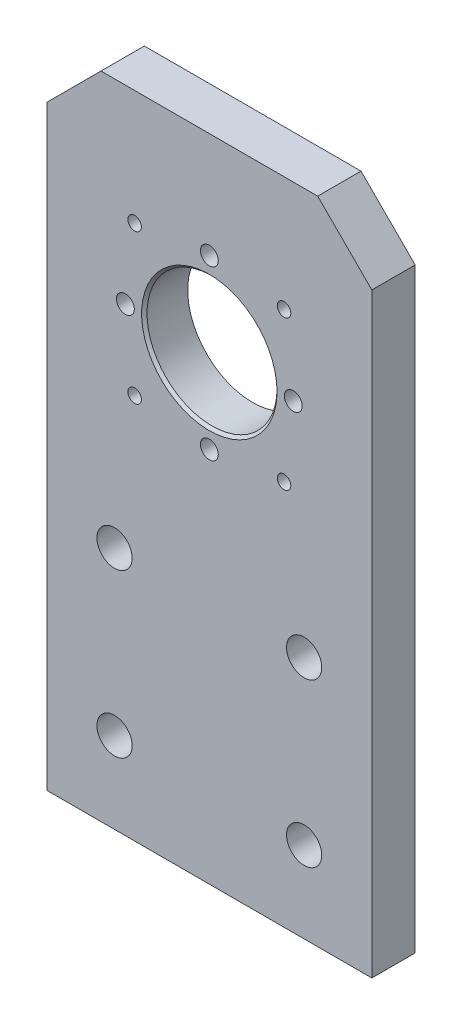
from build123d import *

# Parameters (mm, degrees)
SKETCH1_W           = 60
SKETCH1_H           = 120
SKETCH1_R           = 3.25
SKETCH1_R_2         = 12
BOSS_EXTRUDE1_DEPTH = 8
M3_TAPPED_HOLE1_D   = 2.5
M4_TAPPED_HOLE1_D   = 3.3
CHAMFER1_SIZE       = 0.5
CHAMFER2_SIZE       = 10


with BuildPart() as part:
    # Sketch1 → Boss-Extrude1 (new body)
    with BuildSketch(Plane.XY):
        Rectangle(SKETCH1_W, SKETCH1_H)
        with Locations((-17.5, -15)):
            Circle(SKETCH1_R, mode=Mode.SUBTRACT)
        with Locations((-17.5, -45)):
            Circle(SKETCH1_R, mode=Mode.SUBTRACT)
        with Locations((17.5, -45)):
            Circle(SKETCH1_R, mode=Mode.SUBTRACT)
        with Locations((17.5, -15)):
            Circle(SKETCH1_R, mode=Mode.SUBTRACT)
        with Locations((0, 25)):
            Circle(SKETCH1_R_2, mode=Mode.SUBTRACT)
    extrude(amount=BOSS_EXTRUDE1_DEPTH)

    # M3 Tapped Hole1 (through all)
    with Locations(Plane.XY.offset(8)):
        with Locations((-13.788582233, 38.788582233), (-13.788582233, 11.211417767), (13.788582233, 11.211417767), (13.788582233, 38.788582233)):
            Hole(M3_TAPPED_HOLE1_D / 2)

    # M4 Tapped Hole1 (through all)
    with Locations(Plane.XY.offset(8)):
        with Locations((-15.5, 25), (0, 40.5), (15.5, 25), (0, 9.5)):
            Hole(M4_TAPPED_HOLE1_D / 2)

    # Chamfer1
    chamfer1_edges = [part.edges().sort_by_distance(p)[0] for p in [
        (-12, 25, 8),
    ]]
    chamfer(chamfer1_edges, length=CHAMFER1_SIZE)

    # Chamfer2
    chamfer2_edges = [part.edges().sort_by_distance(p)[0] for p in [
        (-30, 60, 4),
        (30, 60, 4),
    ]]
    chamfer(chamfer2_edges, length=CHAMFER2_SIZE)


solid = part.part
